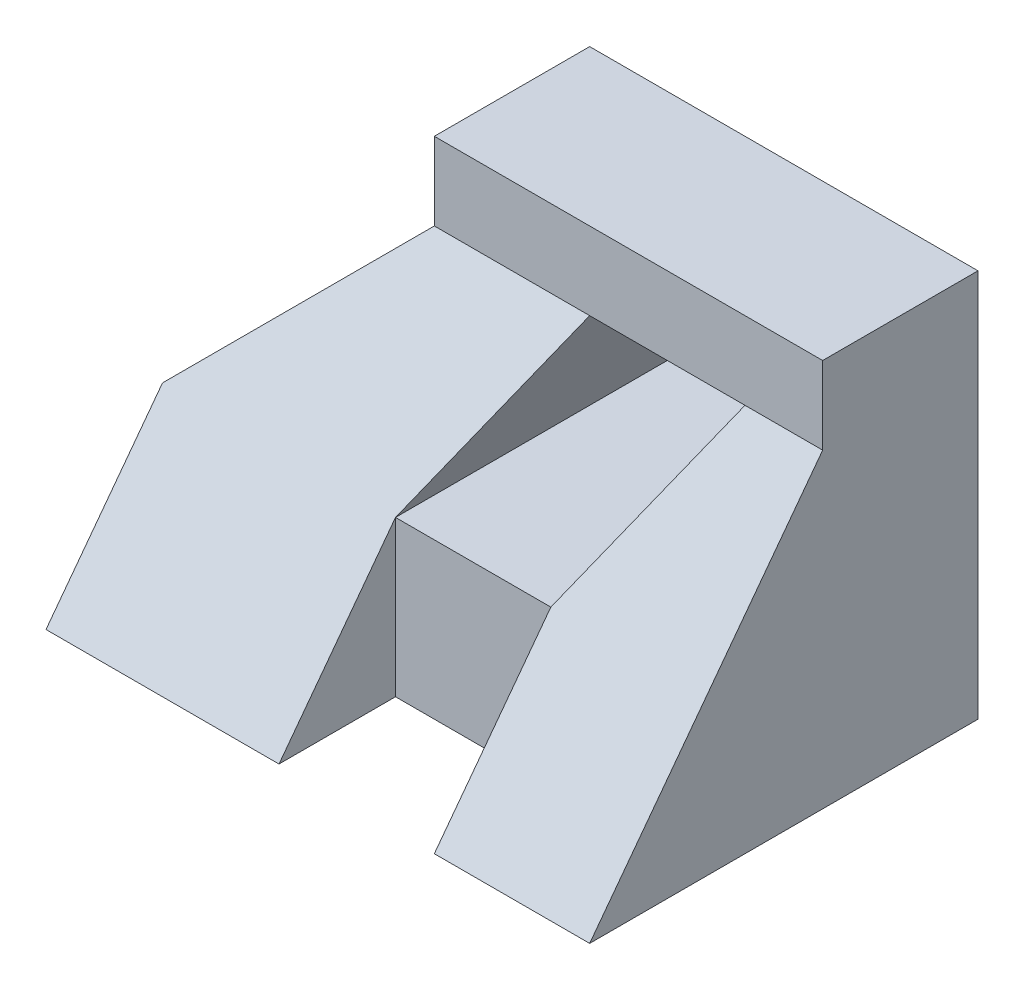
from build123d import *

# Parameters (mm, degrees)
BOSS_EXTRUDE1_DEPTH = 50
SKETCH2_W           = 20
SKETCH2_H           = 20
CUT_EXTRUDE1_DEPTH  = 20
CUT_EXTRUDE2_DEPTH  = 10
SKETCH4_W           = 50
SKETCH4_H           = 10
BOSS_EXTRUDE2_DEPTH = 50
SKETCH5_W           = 50
SKETCH5_H           = 10
CUT_EXTRUDE5_DEPTH  = 30
SKETCH6_W           = 20
SKETCH6_H           = 20
BOSS_EXTRUDE4_DEPTH = 5
CUT_EXTRUDE8_DEPTH  = 40
CUT_EXTRUDE9_DEPTH  = 70


with BuildPart() as part:
    # Sketch1 → Boss-Extrude1 (new body)
    with BuildSketch(Plane.XY):
        Polygon((0, 0), (0, 20), (20, 40), (70, 40), (70, 0), align=None)
    extrude(amount=BOSS_EXTRUDE1_DEPTH)

    # Sketch2 → Cut-Extrude1 (cut)
    with BuildSketch(Plane.XY.offset(50)):
        with Locations((40, 10)):
            Rectangle(SKETCH2_W, SKETCH2_H)
    extrude(amount=-CUT_EXTRUDE1_DEPTH, mode=Mode.SUBTRACT)

    # Sketch3 → Cut-Extrude2 (cut)
    with BuildSketch(Plane.XY.offset(50)):
        Polygon((30, 20), (40, 40), (60, 40), (50, 20), align=None)
    extrude(amount=-CUT_EXTRUDE2_DEPTH, mode=Mode.SUBTRACT)

    # Sketch4 → Boss-Extrude2 (add)
    with BuildSketch(Plane.XY.offset(50)):
        with Locations((45, 45)):
            Rectangle(SKETCH4_W, SKETCH4_H)
    extrude(amount=-BOSS_EXTRUDE2_DEPTH)

    # Sketch5 → Cut-Extrude5 (cut)
    with BuildSketch(Plane.XY.offset(50)):
        with Locations((45, 45)):
            Rectangle(SKETCH5_W, SKETCH5_H)
    extrude(amount=-CUT_EXTRUDE5_DEPTH, mode=Mode.SUBTRACT)

    # Sketch6 → Boss-Extrude4 (add)
    with BuildSketch(Plane.XY.offset(30)):
        with Locations((40, 10)):
            Rectangle(SKETCH6_W, SKETCH6_H)
    extrude(amount=BOSS_EXTRUDE4_DEPTH)

    # Sketch8 → Cut-Extrude8 (cut)
    with BuildSketch(Plane.XY.offset(40)):
        Polygon((40, 40), (60, 40), (50, 20), (30, 20), align=None)
    extrude(amount=-CUT_EXTRUDE8_DEPTH, mode=Mode.SUBTRACT)

    # Sketch9 → Cut-Extrude9 (cut)
    with BuildSketch(Plane.ZY):
        Polygon((20, 40), (35, 20), (50, 20), (50, 40), align=None)
        Polygon((35, 20), (50, 0), (50, 20), align=None)
    extrude(amount=-CUT_EXTRUDE9_DEPTH, mode=Mode.SUBTRACT)


solid = part.part
